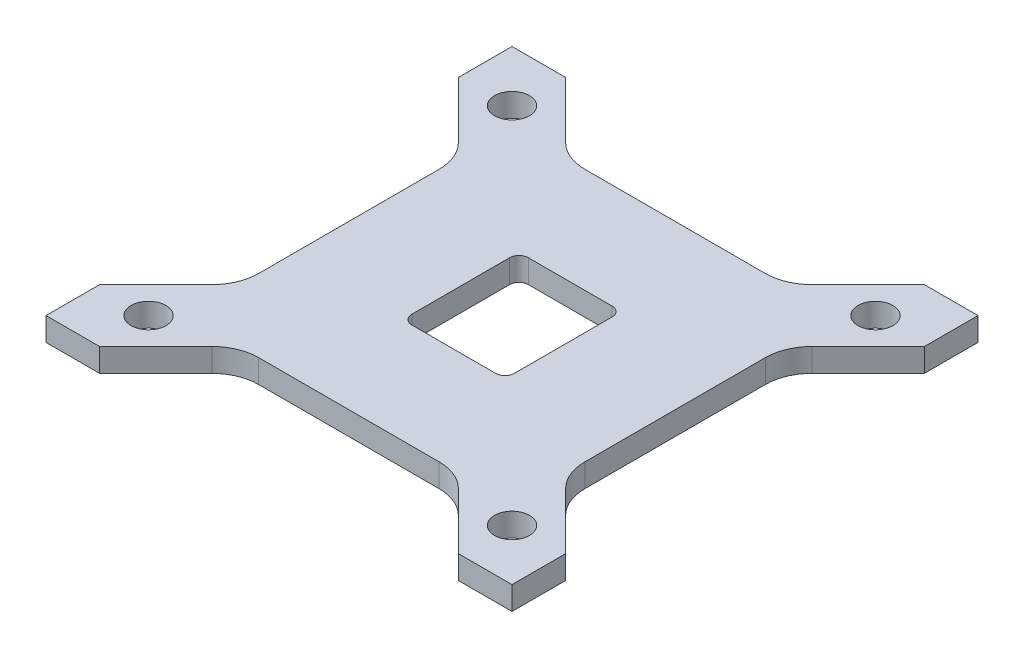
from build123d import *

# Parameters (mm, degrees)
EXTRUDE_1_DEPTH     = 5
SKETCH_2_R          = 3.75
CUT_EXTRUDE_1_DEPTH = 6
FILLET_1_R          = 10
SKETCH_3_W          = 22
SKETCH_3_H          = 25
CUT_EXTRUDE_2_DEPTH = 6
FILLET_2_R          = 2


with BuildPart() as part:
    # ｽｹｯﾁ1 → ﾎﾞｽ - 押し出し1 (new body)
    with BuildSketch(Plane(origin=(0, 0, 0), x_dir=(1, 0, 0), z_dir=(0, 1, 0))):
        Polygon((-50, 38.5), (-50, 50), (-38.5, 50), (-23.5, 35), (23.5, 35), (38.5, 50), (50, 50), (50, 38.5), (35, 23.5), (35, -23.5), (50, -38.5), (50, -50), (38.5, -50), (23.5, -35), (-23.5, -35), (-38.5, -50), (-50, -50), (-50, -38.5), (-35, -23.5), (-35, 23.5), align=None)
    extrude(amount=EXTRUDE_1_DEPTH)

    # ｽｹｯﾁ2 → ｶｯﾄ - 押し出し1 (cut, through all)
    with BuildSketch(Plane(origin=(0, 5, 0), x_dir=(1, 0, 0), z_dir=(0, 1, 0))):
        with Locations((-39, 39)):
            Circle(SKETCH_2_R)
        with Locations((39, 39)):
            Circle(SKETCH_2_R)
        with Locations((39, -39)):
            Circle(SKETCH_2_R)
        with Locations((-39, -39)):
            Circle(SKETCH_2_R)
    extrude(amount=-CUT_EXTRUDE_1_DEPTH, mode=Mode.SUBTRACT)

    # ﾌｨﾚｯﾄ1
    fillet_1_edges = [part.edges().sort_by_distance(p)[0] for p in [
        (-23.5, 2.5, -35),
        (23.5, 2.5, -35),
        (35, 2.5, -23.5),
        (35, 2.5, 23.5),
        (23.5, 2.5, 35),
        (-23.5, 2.5, 35),
        (-35, 2.5, 23.5),
        (-35, 2.5, -23.5),
    ]]
    fillet(fillet_1_edges, radius=FILLET_1_R)

    # ｽｹｯﾁ3 → ｶｯﾄ - 押し出し2 (cut, through all)
    with BuildSketch(Plane(origin=(0, 5, 0), x_dir=(1, 0, 0), z_dir=(0, 1, 0))):
        Rectangle(SKETCH_3_W, SKETCH_3_H)
    extrude(amount=-CUT_EXTRUDE_2_DEPTH, mode=Mode.SUBTRACT)

    # ﾌｨﾚｯﾄ2
    fillet_2_edges = [part.edges().sort_by_distance(p)[0] for p in [
        (11, 2.5, -12.5),
        (11, 2.5, 12.5),
        (-11, 2.5, 12.5),
        (-11, 2.5, -12.5),
    ]]
    fillet(fillet_2_edges, radius=FILLET_2_R)


solid = part.part
